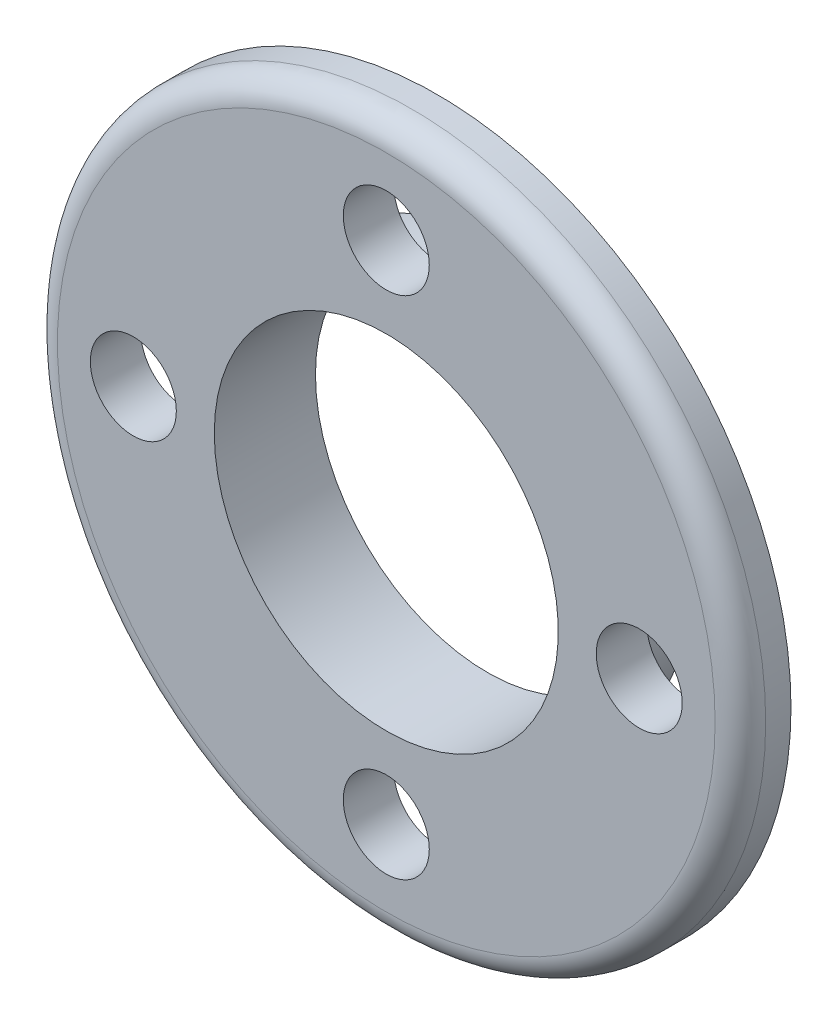
from build123d import *

# Parameters (mm, degrees)
CIRPATTERN1_COUNT = 4
FILLET1_R         = 1


with BuildPart() as part:
    # Sketch1 → Revolve1 (revolve)
    with BuildSketch(Plane(origin=(0, 0, 0), x_dir=(0, 0, -1), z_dir=(1, 0, 0))):
        Polygon((-1, 14), (1, 14), (1, 8), (3, 8), (3, 6.8), (-1, 6.8), align=None)
    revolve(axis=Axis((0, 0, -88.99), (0, 0, 1)))

    # Sketch4 → M3 Clearance Hole1 (revolve, cut)
    with BuildSketch(Plane(origin=(10, 0, 1), x_dir=(0, -1, 0), z_dir=(1, 0, 0))):
        Polygon((0, 0), (0, 9.021463052), (1.7, 8), (1.7, 0), align=None)
    m3_clearance_hole1 = revolve(axis=Axis((10, 0, 7.35), (0, 0, -1)), mode=Mode.SUBTRACT)

    # CirPattern1: M3 Clearance Hole1 ×4 about axis
    cirpattern1_axis = Axis((0, 0, -88.99), (0, 0, 1))
    for i in range(1, CIRPATTERN1_COUNT):
        add(m3_clearance_hole1.rotate(cirpattern1_axis, i * 360 / CIRPATTERN1_COUNT), mode=Mode.SUBTRACT)

    # Fillet1
    fillet1_edges = [part.edges().sort_by_distance(p)[0] for p in [
        (0, -14, 1),
    ]]
    fillet(fillet1_edges, radius=FILLET1_R)


solid = part.part
